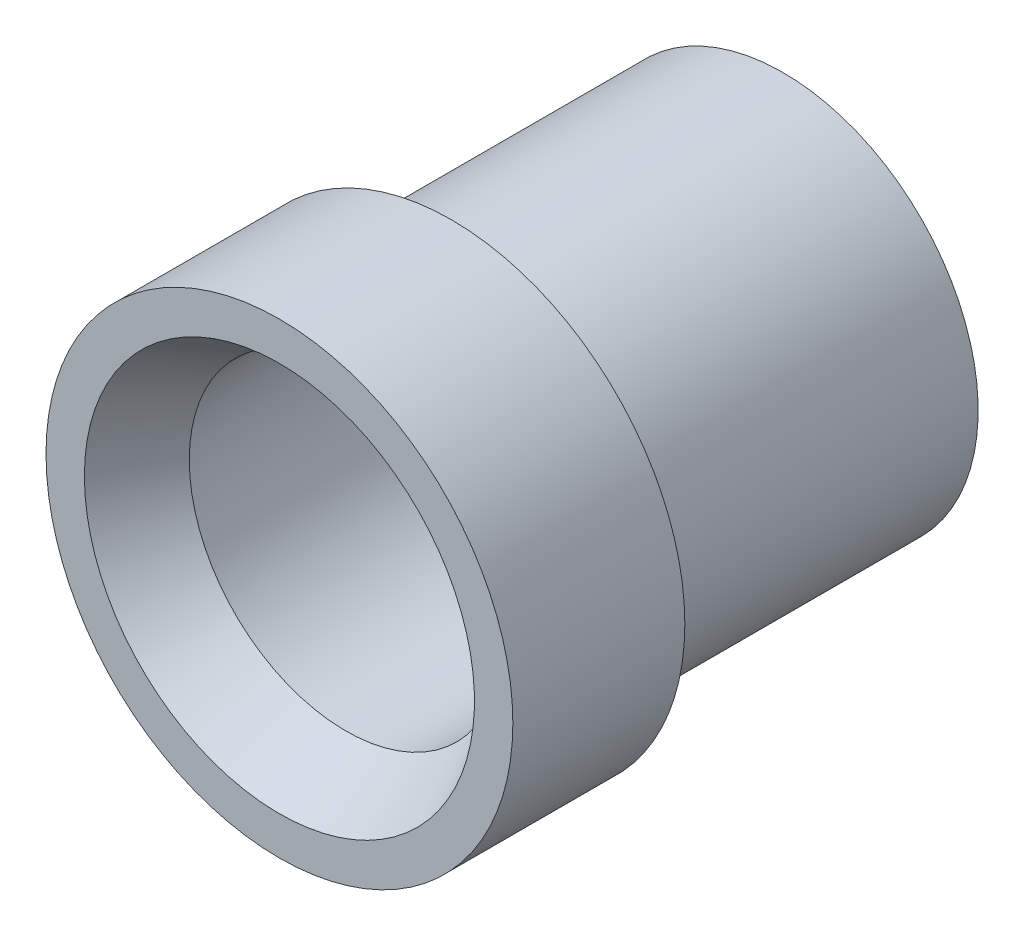
from build123d import *


with BuildPart() as part:
    # Sketch1 → Revolve1 (revolve)
    with BuildSketch(Plane(origin=(0, 0, 0), x_dir=(0, 0, -1), z_dir=(1, 0, 0))):
        Polygon((-5.207, 4.03225), (-3.832184671, 3.2385), (5.207, 3.2385), (5.207, 4.03225), (-1.651, 4.03225), (-1.651, 4.826), (-5.207, 4.826), align=None)
    revolve(axis=Axis((0, 0, -5.207), (0, 0, 1)))


solid = part.part
